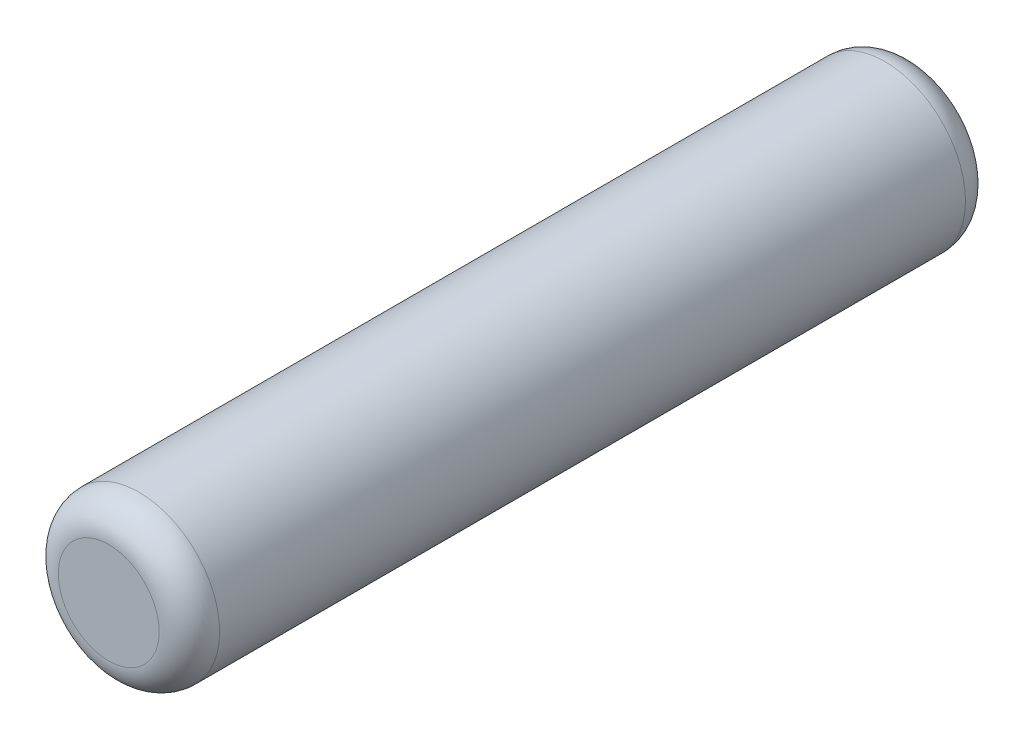
from build123d import *

# Parameters (mm, degrees)
ESQUISSE1_R        = 4
BOSS_EXTRU_1_DEPTH = 20
CONG_1_R           = 1.5


with BuildPart() as part:
    # Esquisse1 → Boss.-Extru.1 (new body, symmetric)
    with BuildSketch(Plane.XY):
        Circle(ESQUISSE1_R)
    extrude(amount=BOSS_EXTRU_1_DEPTH, both=True)

    # Congé1
    cong_1_edges = [part.edges().sort_by_distance(p)[0] for p in [
        (-4, 0, -20),
        (-4, 0, 20),
    ]]
    fillet(cong_1_edges, radius=CONG_1_R)


solid = part.part
